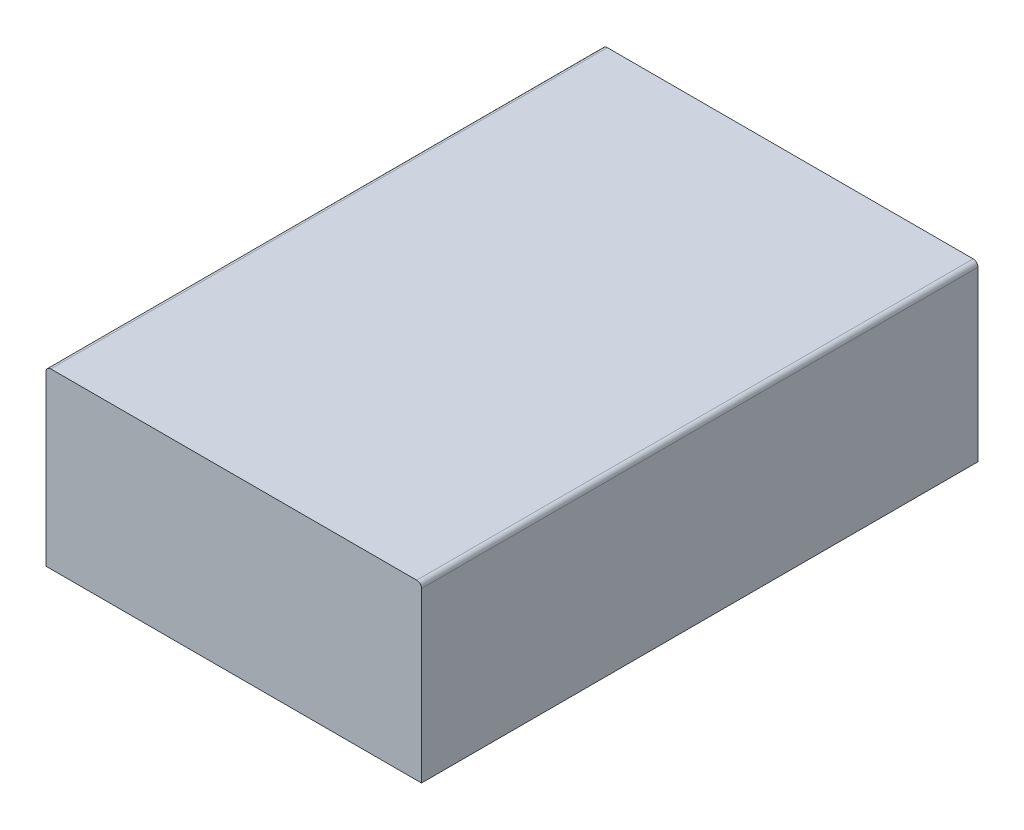
from build123d import *

# Parameters (mm, degrees)
SKETCH_1_W      = 39
SKETCH_1_H      = 57.8
EXTRUDE_1_DEPTH = 18
FILLET_1_R      = 0.5


with BuildPart() as part:
    # 草图1 → 凸台-拉伸1 (new body)
    with BuildSketch(Plane(origin=(0, 0, 0), x_dir=(1, 0, 0), z_dir=(0, 1, 0))):
        Rectangle(SKETCH_1_W, SKETCH_1_H)
    extrude(amount=EXTRUDE_1_DEPTH)

    # 圆角1
    fillet_1_edges = [part.edges().sort_by_distance(p)[0] for p in [
        (-19.5, 18, 0),
        (19.5, 18, 0),
    ]]
    fillet(fillet_1_edges, radius=FILLET_1_R)


solid = part.part
